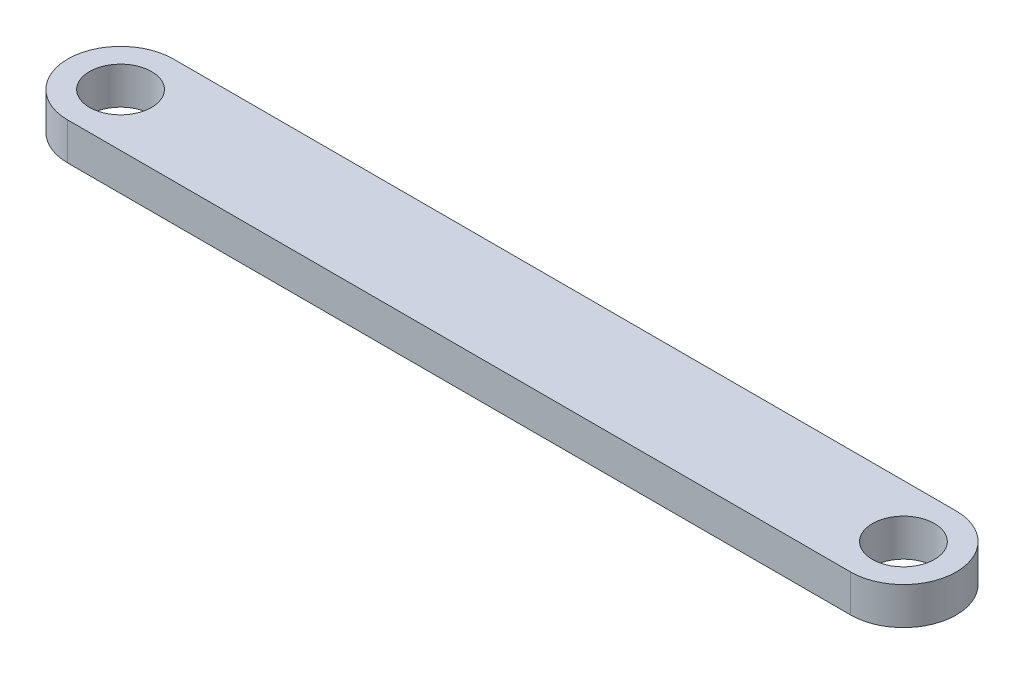
from build123d import *

# Parameters (mm, degrees)
BOSS_EXTRUDE1_DEPTH = 3
SKETCH4_R           = 2.5
CUT_EXTRUDE2_DEPTH  = 4


with BuildPart() as part:
    # Sketch2 → Boss-Extrude1 (new body)
    with BuildSketch(Plane(origin=(0, 0, 0), x_dir=(1, 0, 0), z_dir=(0, 1, 0))):
        with BuildLine():
            Line((0, -4.25), (63, -4.25))
            ThreePointArc((63, -4.25), (67.25, 0), (63, 4.25))
            Line((63, 4.25), (0, 4.25))
            ThreePointArc((0, 4.25), (-4.25, 0), (0, -4.25))
        make_face()
    extrude(amount=BOSS_EXTRUDE1_DEPTH)

    # Sketch4 → Cut-Extrude2 (cut, through all)
    with BuildSketch(Plane(origin=(0, 3, 0), x_dir=(1, 0, 0), z_dir=(0, 1, 0))):
        Circle(SKETCH4_R)
        with Locations((63, 0)):
            Circle(SKETCH4_R)
    extrude(amount=-CUT_EXTRUDE2_DEPTH, mode=Mode.SUBTRACT)


solid = part.part
